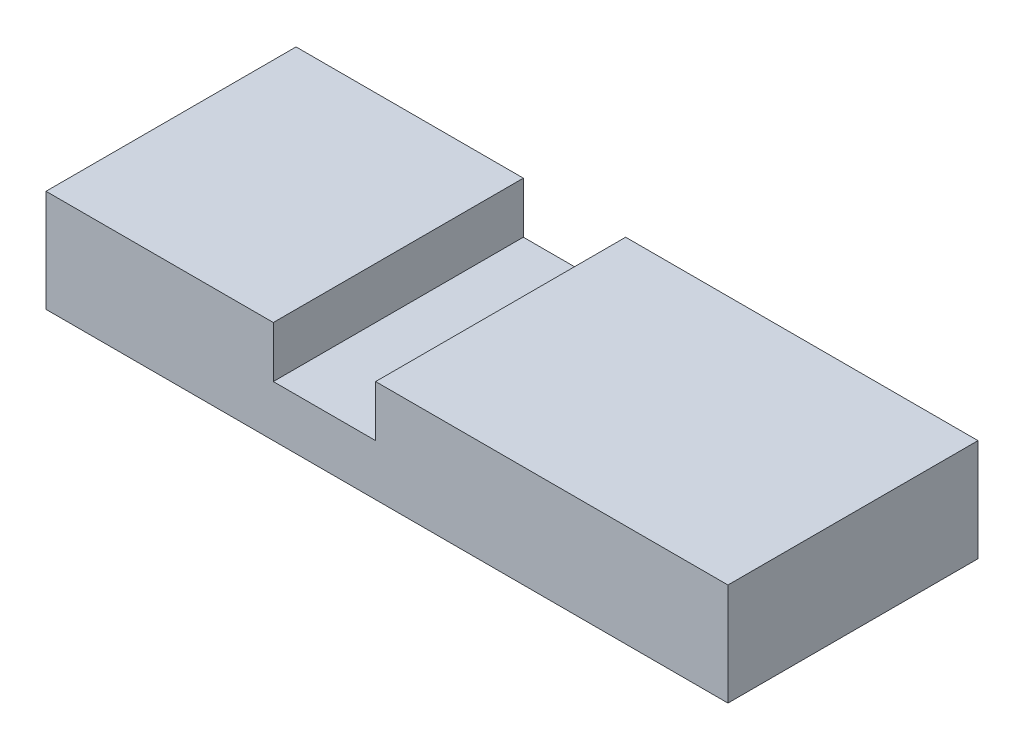
from build123d import *

# Parameters (mm, degrees)
SKETCH1_W      = 120
SKETCH1_H      = 44
EXTRUDE1_DEPTH = 18
EXTRUDE2_REACH = 46
SKETCH2_W      = 18
SKETCH2_H      = 9


with BuildPart() as part:
    # Sketch1 → Extrude1 (new body)
    with BuildSketch(Plane(origin=(0, 0, 0), x_dir=(1, 0, 0), z_dir=(0, 1, 0))):
        with Locations((-60, 22)):
            Rectangle(SKETCH1_W, SKETCH1_H)
    extrude(amount=EXTRUDE1_DEPTH)

    # Sketch2 → Extrude2 (cut, up to next)
    with BuildSketch(Plane.XY, mode=Mode.PRIVATE) as extrude2_sk1:
        with Locations((-71, 13.5)):
            Rectangle(SKETCH2_W, SKETCH2_H)
    extrude2_tool1 = extrude(extrude2_sk1.sketch, amount=-EXTRUDE2_REACH, mode=Mode.PRIVATE) & part.part
    add(extrude2_tool1.solids().sort_by_distance((-71, 13.5, 0))[0], mode=Mode.SUBTRACT)


solid = part.part
